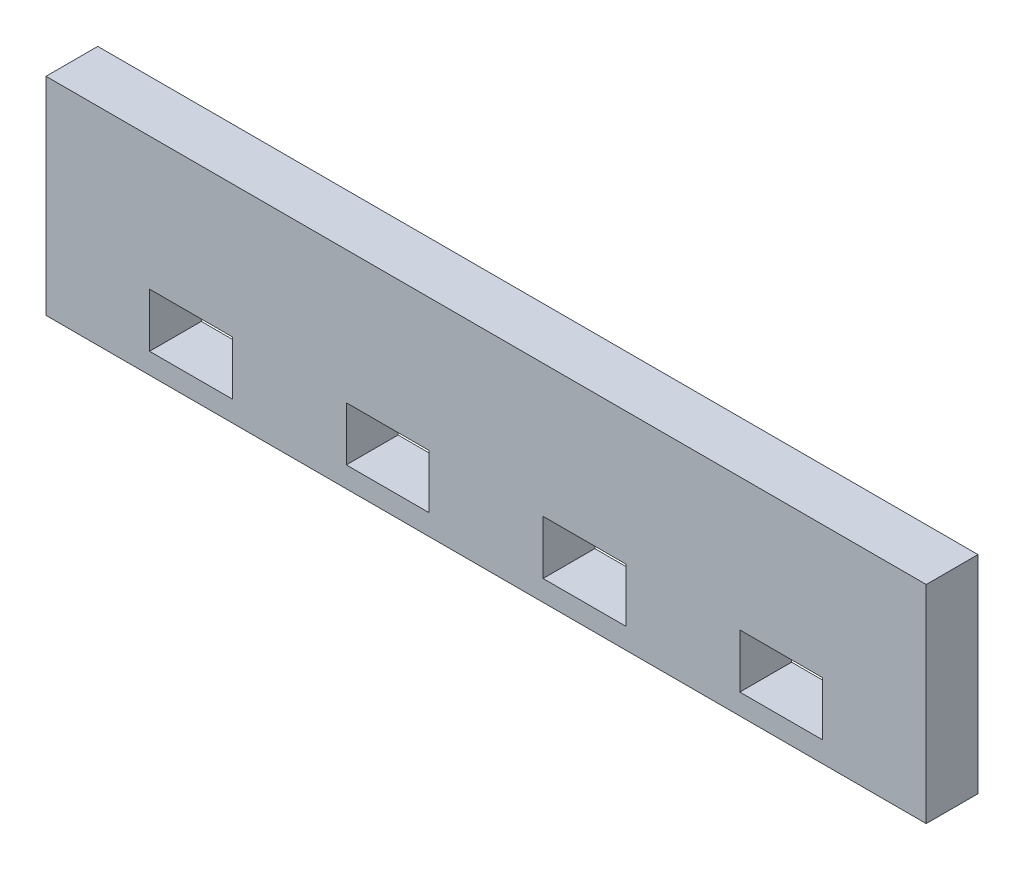
from build123d import *

# Parameters (mm, degrees)
SKETCH1_W           = 85
SKETCH1_H           = 20
BOSS_EXTRUDE1_DEPTH = 5
CUT_EXTRUDE1_REACH  = 7
SKETCH2_W           = 8
SKETCH2_H           = 5.2


with BuildPart() as part:
    # Sketch1 → Boss-Extrude1 (new body)
    with BuildSketch(Plane.XY):
        with Locations((20.528766582, 10)):
            Rectangle(SKETCH1_W, SKETCH1_H)
    extrude(amount=BOSS_EXTRUDE1_DEPTH)

    # Sketch2 → Cut-Extrude1 (cut, up to next)
    with BuildSketch(Plane.XY.offset(5), mode=Mode.PRIVATE) as cut_extrude1_sk1:
        with Locations((-7.971233418, 4.6)):
            Rectangle(SKETCH2_W, SKETCH2_H)
    cut_extrude1_tool1 = extrude(cut_extrude1_sk1.sketch, amount=-CUT_EXTRUDE1_REACH, mode=Mode.PRIVATE) & part.part
    add(cut_extrude1_tool1.solids().sort_by_distance((-7.971233, 4.6, 5))[0], mode=Mode.SUBTRACT)
    # Sketch2 → Cut-Extrude1 (cut, up to next)
    with BuildSketch(Plane.XY.offset(5), mode=Mode.PRIVATE) as cut_extrude1_sk2:
        with Locations((11.028766582, 4.6)):
            Rectangle(SKETCH2_W, SKETCH2_H)
    cut_extrude1_tool2 = extrude(cut_extrude1_sk2.sketch, amount=-CUT_EXTRUDE1_REACH, mode=Mode.PRIVATE) & part.part
    add(cut_extrude1_tool2.solids().sort_by_distance((11.028767, 4.6, 5))[0], mode=Mode.SUBTRACT)
    # Sketch2 → Cut-Extrude1 (cut, up to next)
    with BuildSketch(Plane.XY.offset(5), mode=Mode.PRIVATE) as cut_extrude1_sk3:
        with Locations((30.028766582, 4.6)):
            Rectangle(SKETCH2_W, SKETCH2_H)
    cut_extrude1_tool3 = extrude(cut_extrude1_sk3.sketch, amount=-CUT_EXTRUDE1_REACH, mode=Mode.PRIVATE) & part.part
    add(cut_extrude1_tool3.solids().sort_by_distance((30.028767, 4.6, 5))[0], mode=Mode.SUBTRACT)
    # Sketch2 → Cut-Extrude1 (cut, up to next)
    with BuildSketch(Plane.XY.offset(5), mode=Mode.PRIVATE) as cut_extrude1_sk4:
        with Locations((49.028766582, 4.6)):
            Rectangle(SKETCH2_W, SKETCH2_H)
    cut_extrude1_tool4 = extrude(cut_extrude1_sk4.sketch, amount=-CUT_EXTRUDE1_REACH, mode=Mode.PRIVATE) & part.part
    add(cut_extrude1_tool4.solids().sort_by_distance((49.028767, 4.6, 5))[0], mode=Mode.SUBTRACT)


solid = part.part
